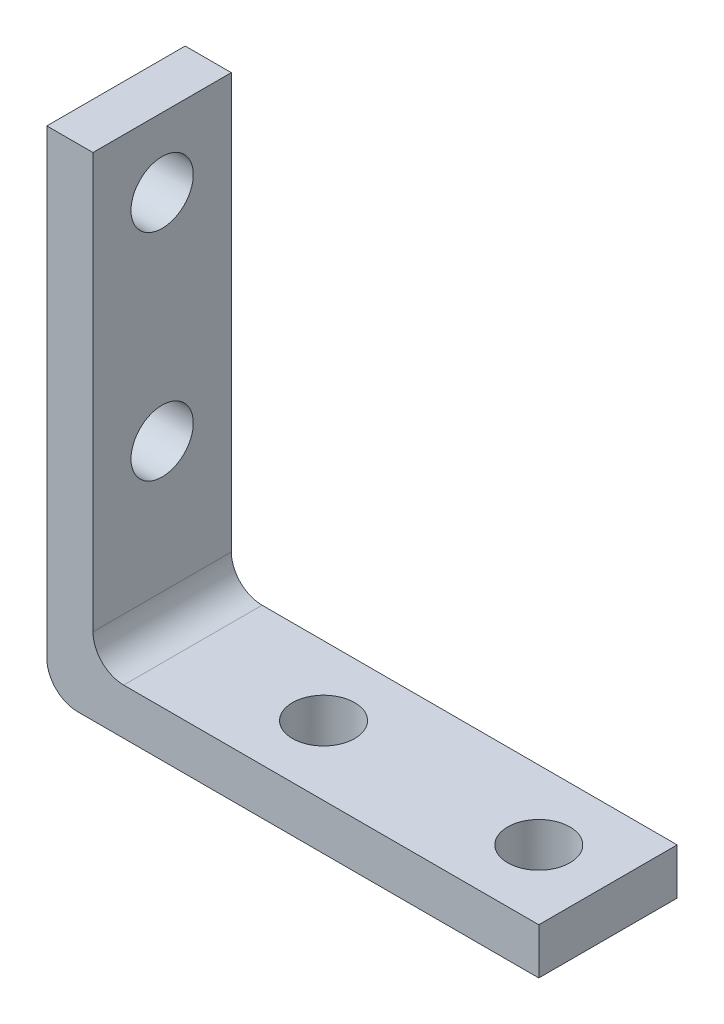
from build123d import *

# Parameters (mm, degrees)
SKETCH_1_W          = 3
SKETCH_1_H          = 29
SKETCH_1_W_2        = 32
SKETCH_1_H_2        = 3
EXTRUDE_1_DEPTH     = 4.5
SKETCH_3_R          = 2.025
CUT_EXTRUDE_1_DEPTH = 9
SKETCH_4_R          = 2.025
CUT_EXTRUDE_2_DEPTH = 9
FILLET_1_R          = 2


with BuildPart() as part:
    # 草图1 → 凸台-拉伸1 (new body, symmetric)
    with BuildSketch(Plane.XY):
        with Locations((1.5, 17.5)):
            Rectangle(SKETCH_1_W, SKETCH_1_H)
        with Locations((16, 1.5)):
            Rectangle(SKETCH_1_W_2, SKETCH_1_H_2)
    extrude(amount=EXTRUDE_1_DEPTH, both=True)

    # 草图3 → 切除-拉伸1 (cut)
    with BuildSketch(Plane.XZ):
        with Locations((13.5, 0)):
            Circle(SKETCH_3_R)
        with Locations((27.5, 0)):
            Circle(SKETCH_3_R)
    extrude(amount=-CUT_EXTRUDE_1_DEPTH, mode=Mode.SUBTRACT)

    # 草图4 → 切除-拉伸2 (cut)
    with BuildSketch(Plane.ZY):
        with Locations((0, 27.5)):
            Circle(SKETCH_4_R)
        with Locations((0, 13.5)):
            Circle(SKETCH_4_R)
    extrude(amount=-CUT_EXTRUDE_2_DEPTH, mode=Mode.SUBTRACT)

    # 圆角1
    fillet_1_edges = [part.edges().sort_by_distance(p)[0] for p in [
        (3, 3, 0),
        (0, 0, 0),
    ]]
    fillet(fillet_1_edges, radius=FILLET_1_R)


solid = part.part
